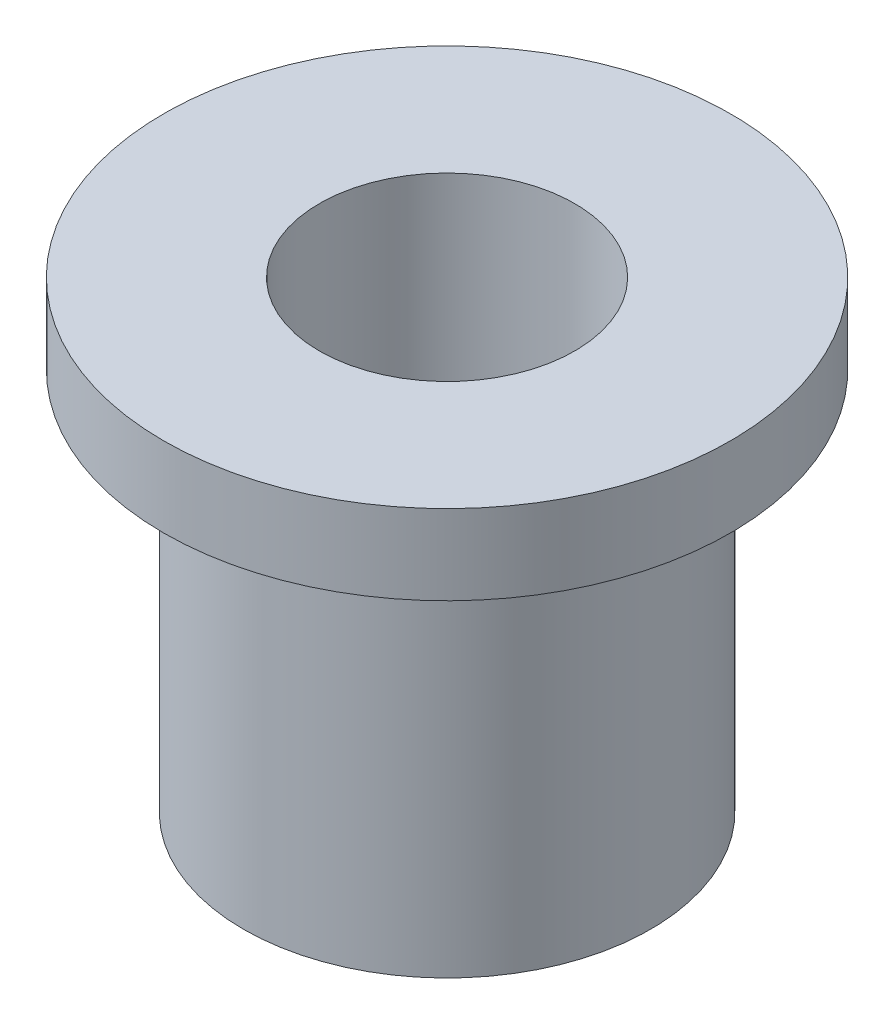
from build123d import *

# Parameters (mm, degrees)
SKETCH1_R           = 2.55
SKETCH1_R_2         = 1.6
BOSS_EXTRUDE1_DEPTH = 5.8
SKETCH2_R           = 3.55
SKETCH2_R_2         = 1.6
BOSS_EXTRUDE2_DEPTH = 1


with BuildPart() as part:
    # Sketch1 → Boss-Extrude1 (new body)
    with BuildSketch(Plane(origin=(0, 0, 0), x_dir=(1, 0, 0), z_dir=(0, 1, 0))):
        Circle(SKETCH1_R)
        Circle(SKETCH1_R_2, mode=Mode.SUBTRACT)
    extrude(amount=BOSS_EXTRUDE1_DEPTH)

    # Sketch2 → Boss-Extrude2 (add)
    with BuildSketch(Plane(origin=(0, 5.8, 0), x_dir=(1, 0, 0), z_dir=(0, 1, 0))):
        Circle(SKETCH2_R)
        Circle(SKETCH2_R_2, mode=Mode.SUBTRACT)
    extrude(amount=-BOSS_EXTRUDE2_DEPTH)


solid = part.part
